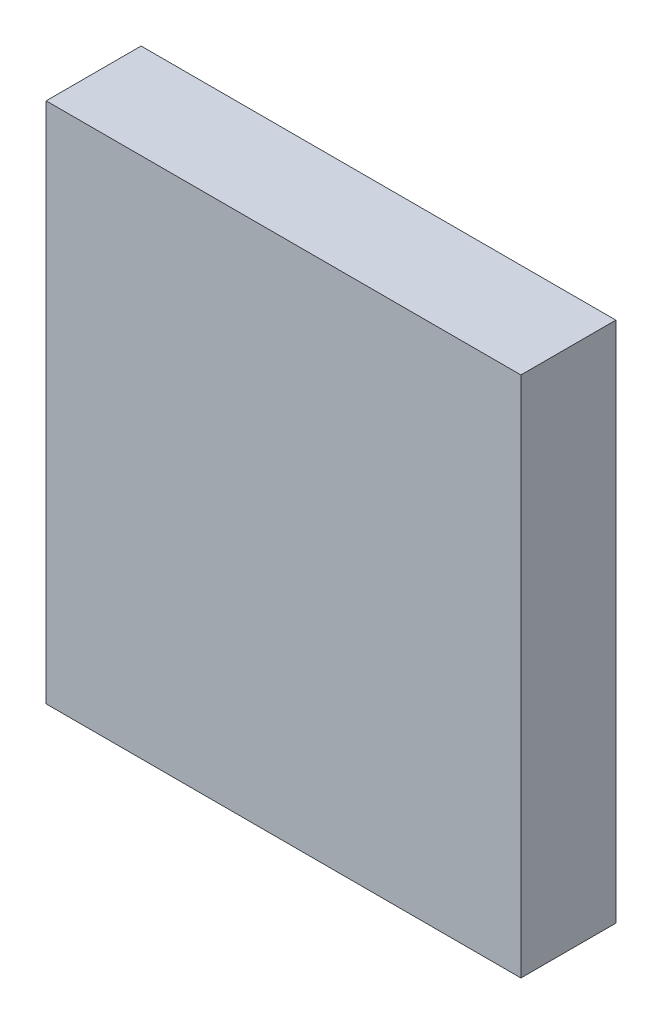
from build123d import *

# Parameters (mm, degrees)
SKETCH1_W           = 25
SKETCH1_H           = 27.5
BOSS_EXTRUDE1_DEPTH = 5


with BuildPart() as part:
    # Sketch1 → Boss-Extrude1 (new body)
    with BuildSketch(Plane.XY):
        Rectangle(SKETCH1_W, SKETCH1_H)
    extrude(amount=BOSS_EXTRUDE1_DEPTH)


solid = part.part
